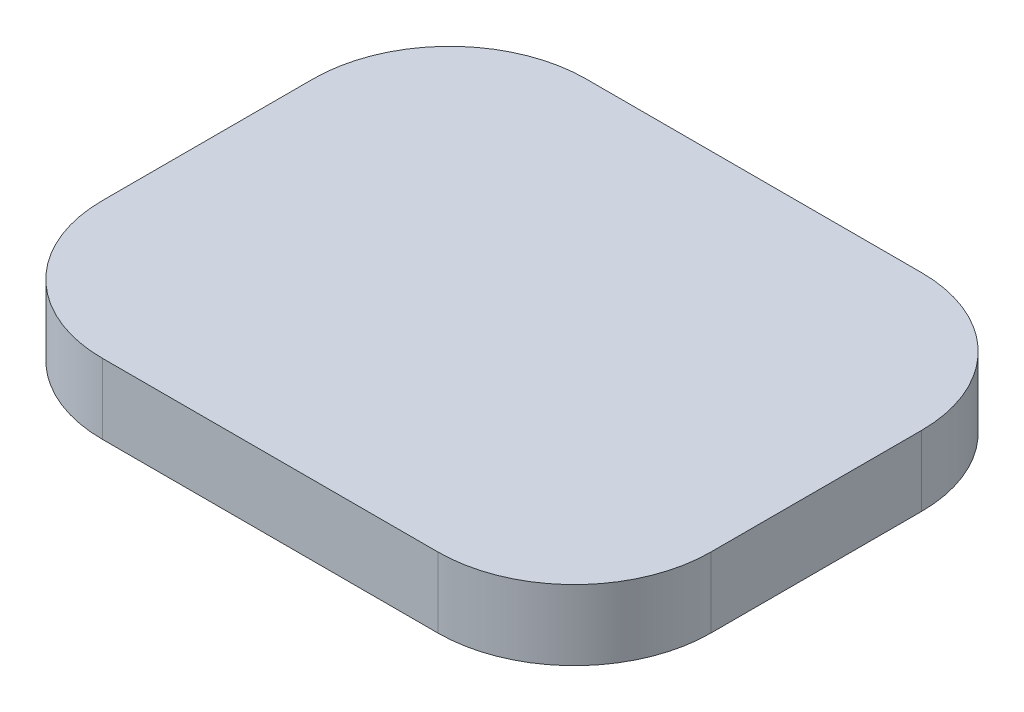
from build123d import *

# Parameters (mm, degrees)
ESQUISSE1_W        = 78
ESQUISSE1_H        = 62
BOSS_EXTRU_1_DEPTH = 9
CONG_1_R           = 17.5


with BuildPart() as part:
    # Esquisse1 → Boss.-Extru.1 (new body)
    with BuildSketch(Plane(origin=(0, 0, 0), x_dir=(1, 0, 0), z_dir=(0, 1, 0))):
        Rectangle(ESQUISSE1_W, ESQUISSE1_H)
    extrude(amount=BOSS_EXTRU_1_DEPTH)

    # Congé1
    cong_1_edges = [part.edges().sort_by_distance(p)[0] for p in [
        (-39, 4.5, -31),
        (39, 4.5, -31),
        (39, 4.5, 31),
        (-39, 4.5, 31),
    ]]
    fillet(cong_1_edges, radius=CONG_1_R)


solid = part.part
